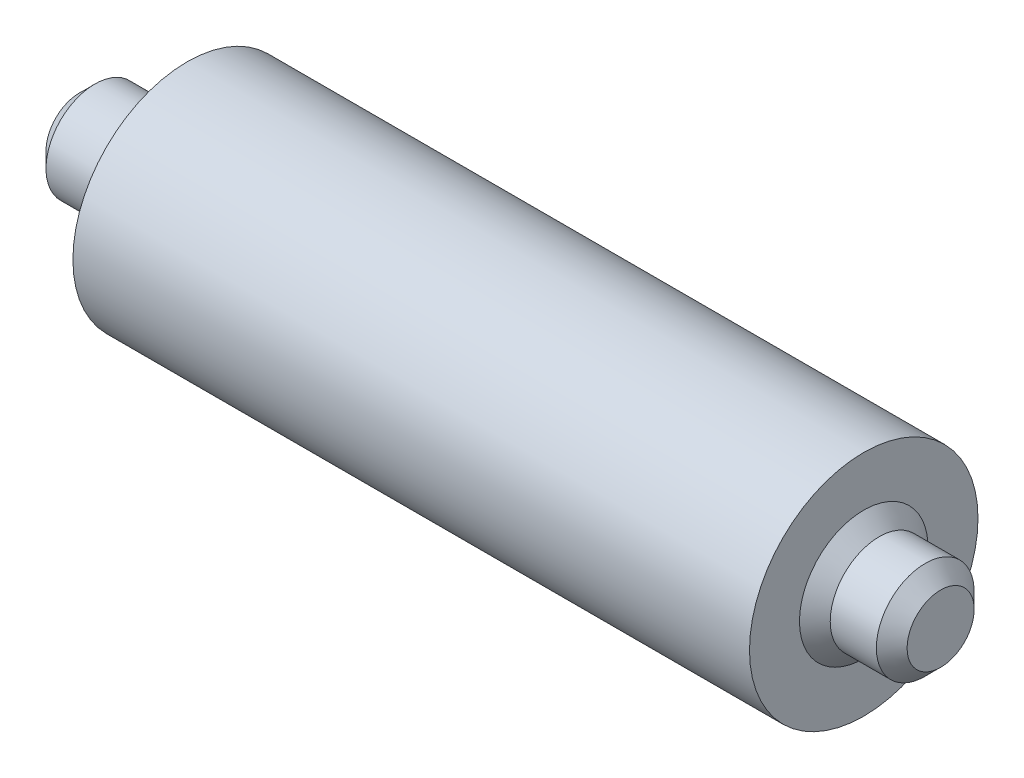
from build123d import *

# Parameters (mm, degrees)
CHAMFER1_SIZE = 1
CHAMFER2_SIZE = 1


with BuildPart() as part:
    # Sketch1 → Revolve1 (revolve)
    with BuildSketch(Plane.XY):
        Polygon((-28.142857143, 0), (-28.142857143, 3.18), (-21.142857143, 3.18), (-21.142857143, 7.43), (22.857142857, 7.43), (22.857142857, 3.18), (27.857142857, 3.18), (27.857142857, 0), align=None)
    revolve(axis=Axis((-28.142857143, 0, 0), (1, 0, 0)))

    # Chamfer1
    chamfer1_edges = [part.edges().sort_by_distance(p)[0] for p in [
        (27.857142857, -3.18, 0),
        (-28.142857143, -3.18, 0),
    ]]
    chamfer(chamfer1_edges, length=CHAMFER1_SIZE)

    # Chamfer2
    chamfer2_edges = [part.edges().sort_by_distance(p)[0] for p in [
        (22.857142857, -3.18, 0),
        (-21.142857143, -3.18, 0),
    ]]
    chamfer(chamfer2_edges, length=CHAMFER2_SIZE)


solid = part.part
